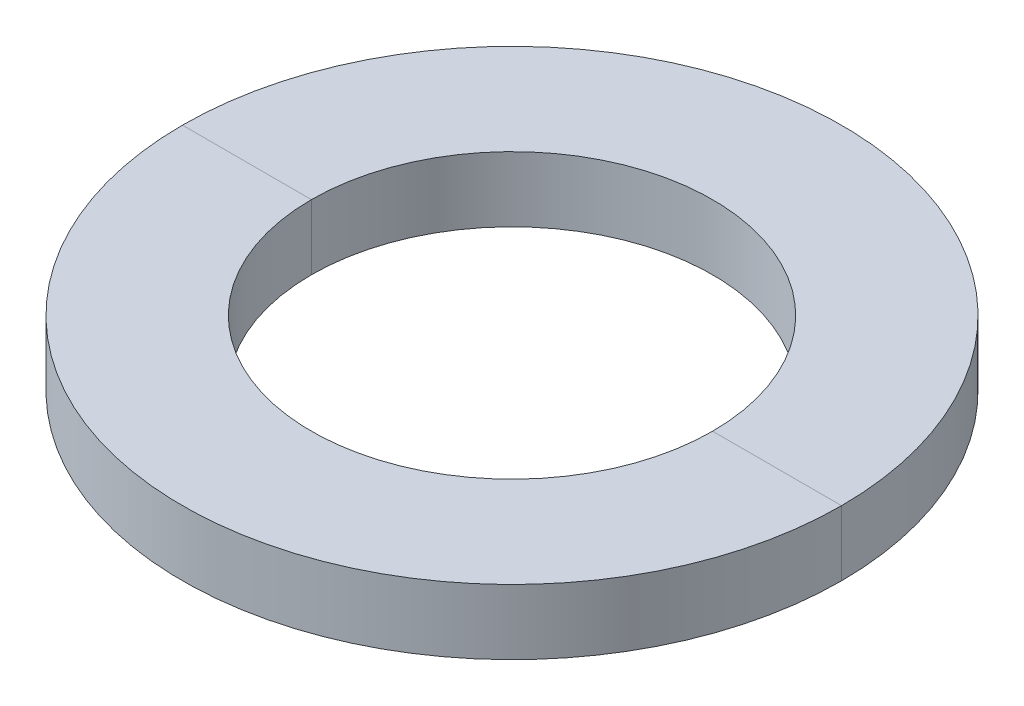
from build123d import *

# Parameters (mm, degrees)
SKETCH1_R      = 18.25625
SKETCH1_R_2    = 11.1125
EXTRUDE1_DEPTH = 3.6068


with BuildPart() as part:
    # Sketch1 → Extrude1 (new body)
    with BuildSketch(Plane(origin=(0, 0, 0), x_dir=(1, 0, 0), z_dir=(0, 1, 0))):
        Circle(SKETCH1_R)
        Circle(SKETCH1_R_2, mode=Mode.SUBTRACT)
    extrude(amount=EXTRUDE1_DEPTH)


with BuildPart() as body_2:
    # Split1: the piece on the far side of the plane
    add(part.part)
    split(bisect_by=Plane.XY, keep=Keep.BOTTOM)


with BuildPart() as part_1:
    add(part.part)

    # Split1
    split(bisect_by=Plane.XY, keep=Keep.TOP)


solid = Compound([body_2.part, part_1.part])
